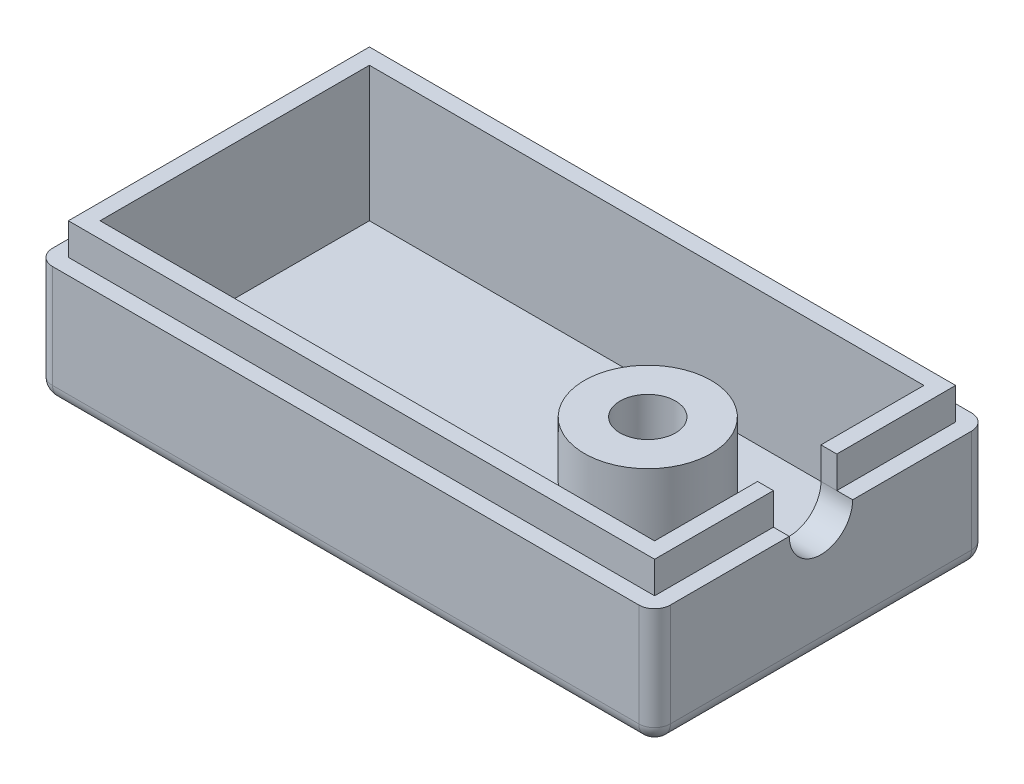
from build123d import *

# Parameters (mm, degrees)
SKETCH1_W           = 39
SKETCH1_H           = 21
BOSS_EXTRUDE1_DEPTH = 7.5
SKETCH2_W           = 37
SKETCH2_H           = 19
CUT_EXTRUDE1_DEPTH  = 6.5
FILLET1_R           = 1
FILLET2_R           = 1
SKETCH3_W           = 37
SKETCH3_H           = 19
BOSS_EXTRUDE2_DEPTH = 8.5
SKETCH4_W           = 35
SKETCH4_H           = 17
CUT_EXTRUDE2_DEPTH  = 8.5
SKETCH5_R           = 4
BOSS_EXTRUDE3_DEPTH = 6.5
SKETCH6_R           = 3
CUT_EXTRUDE3_DEPTH  = 7.5
SKETCH7_R           = 4
BOSS_EXTRUDE4_DEPTH = 4
SKETCH8_R           = 1.75
CUT_EXTRUDE4_DEPTH  = 4
CUT_EXTRUDE5_DEPTH  = 2


with BuildPart() as part:
    # Sketch1 → Boss-Extrude1 (new body)
    with BuildSketch(Plane(origin=(0, 0, 0), x_dir=(1, 0, 0), z_dir=(0, 1, 0))):
        with Locations((19.5, 10.5)):
            Rectangle(SKETCH1_W, SKETCH1_H)
    extrude(amount=BOSS_EXTRUDE1_DEPTH)

    # Sketch2 → Cut-Extrude1 (cut)
    with BuildSketch(Plane(origin=(0, 7.5, 0), x_dir=(1, 0, 0), z_dir=(0, 1, 0))):
        with Locations((19.5, 10.5)):
            Rectangle(SKETCH2_W, SKETCH2_H)
    extrude(amount=-CUT_EXTRUDE1_DEPTH, mode=Mode.SUBTRACT)

    # Fillet1
    fillet1_edges = [part.edges().sort_by_distance(p)[0] for p in [
        (0, 3.75, -21),
        (39, 3.75, -21),
        (39, 3.75, 0),
        (0, 3.75, 0),
    ]]
    fillet(fillet1_edges, radius=FILLET1_R)

    # Fillet2
    fillet2_edges = [part.edges().sort_by_distance(p)[0] for p in [
        (39, 0, -10.5),
        (0, 0, -10.5),
        (19.5, 0, -21),
        (19.5, 0, 0),
        (0.292893219, 0, -0.292893219),
        (0.292893219, 0, -20.707106781),
        (38.707106781, 0, -20.707106781),
        (38.707106781, 0, -0.292893219),
    ]]
    fillet(fillet2_edges, radius=FILLET2_R)

    # Sketch3 → Boss-Extrude2 (add)
    with BuildSketch(Plane(origin=(0, 1, 0), x_dir=(1, 0, 0), z_dir=(0, 1, 0))):
        with Locations((19.5, 10.5)):
            Rectangle(SKETCH3_W, SKETCH3_H)
    extrude(amount=BOSS_EXTRUDE2_DEPTH)

    # Sketch4 → Cut-Extrude2 (cut)
    with BuildSketch(Plane(origin=(0, 9.5, 0), x_dir=(1, 0, 0), z_dir=(0, 1, 0))):
        with Locations((19.5, 10.5)):
            Rectangle(SKETCH4_W, SKETCH4_H)
    extrude(amount=-CUT_EXTRUDE2_DEPTH, mode=Mode.SUBTRACT)

    # Sketch5 → Boss-Extrude3 (add)
    with BuildSketch(Plane(origin=(0, 1, 0), x_dir=(1, 0, 0), z_dir=(0, 1, 0))):
        with Locations((28.01, 10.56)):
            Circle(SKETCH5_R)
    extrude(amount=BOSS_EXTRUDE3_DEPTH)

    # Sketch6 → Cut-Extrude3 (cut)
    with BuildSketch(Plane(origin=(0, 7.5, 0), x_dir=(1, 0, 0), z_dir=(0, 1, 0))):
        with Locations((28.01, 10.56)):
            Circle(SKETCH6_R)
    extrude(amount=-CUT_EXTRUDE3_DEPTH, mode=Mode.SUBTRACT)

    # Sketch7 → Boss-Extrude4 (add)
    with BuildSketch(Plane(origin=(0, 7.5, 0), x_dir=(1, 0, 0), z_dir=(0, 1, 0))):
        with Locations((28.01, 10.56)):
            Circle(SKETCH7_R)
    extrude(amount=-BOSS_EXTRUDE4_DEPTH)

    # Sketch8 → Cut-Extrude4 (cut)
    with BuildSketch(Plane(origin=(0, 7.5, 0), x_dir=(1, 0, 0), z_dir=(0, 1, 0))):
        with Locations((28.01, 10.56)):
            Circle(SKETCH8_R)
    extrude(amount=-CUT_EXTRUDE4_DEPTH, mode=Mode.SUBTRACT)

    # Sketch9 → Cut-Extrude5 (cut)
    with BuildSketch(Plane(origin=(39, 0, 0), x_dir=(0, 0, -1), z_dir=(1, 0, 0))):
        with BuildLine():
            Line((8.5, 7.5), (8.5, 9.5))
            Line((8.5, 9.5), (12.5, 9.5))
            Line((12.5, 9.5), (12.5, 7.5))
            ThreePointArc((12.5, 7.5), (10.5, 5.5), (8.5, 7.5))
        make_face()
    extrude(amount=-CUT_EXTRUDE5_DEPTH, mode=Mode.SUBTRACT)


solid = part.part
